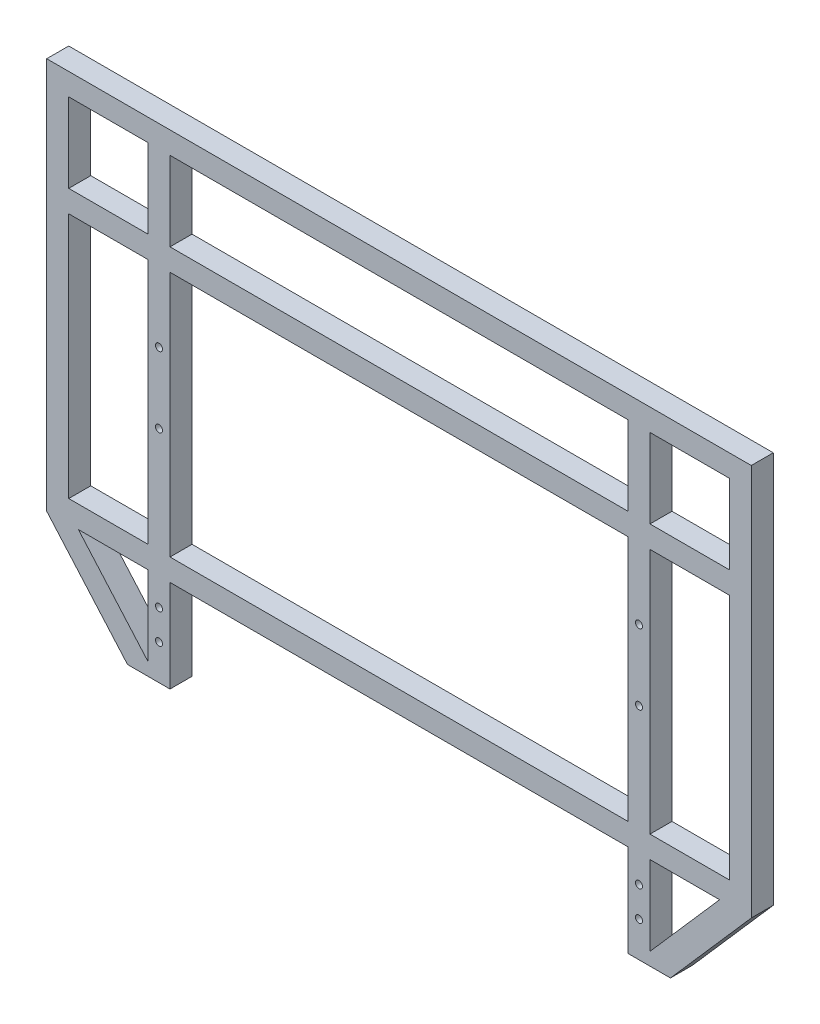
from build123d import *

# Parameters (mm, degrees)
SKETCH1_W           = 45
SKETCH1_H           = 140
SKETCH1_H_2         = 45
SKETCH1_W_2         = 260
BOSS_EXTRUDE1_DEPTH = 12.5
SKETCH2_R           = 2
CUT_EXTRUDE1_DEPTH  = 15
SKETCH3_R           = 2
CUT_EXTRUDE2_DEPTH  = 15


with BuildPart() as part:
    # Sketch1 → Boss-Extrude1 (new body)
    with BuildSketch(Plane.XY):
        Polygon((200, 0), (0, 0), (-200, 0), (-200, -222.5), (-154.126087164, -274.927328955), (-130, -274.927328955), (-130, -222.5), (130, -222.5), (130, -274.927328955), (154.126087164, -274.927328955), (200, -222.5), align=None)
        Polygon((-142.5, -267.654601682), (-182.010276472, -222.5), (-142.5, -222.5), align=None, mode=Mode.SUBTRACT)
        Polygon((142.5, -222.5), (182.010276472, -222.5), (142.5, -267.654601682), align=None, mode=Mode.SUBTRACT)
        with Locations((-165, -140)):
            Rectangle(SKETCH1_W, SKETCH1_H, mode=Mode.SUBTRACT)
        with Locations((-165, -35)):
            Rectangle(SKETCH1_W, SKETCH1_H_2, mode=Mode.SUBTRACT)
        with Locations((0, -35)):
            Rectangle(SKETCH1_W_2, SKETCH1_H_2, mode=Mode.SUBTRACT)
        with Locations((0, -140)):
            Rectangle(SKETCH1_W_2, SKETCH1_H, mode=Mode.SUBTRACT)
        with Locations((165, -140)):
            Rectangle(SKETCH1_W, SKETCH1_H, mode=Mode.SUBTRACT)
        with Locations((165, -35)):
            Rectangle(SKETCH1_W, SKETCH1_H_2, mode=Mode.SUBTRACT)
    extrude(amount=BOSS_EXTRUDE1_DEPTH)

    # Sketch2 → Cut-Extrude1 (cut)
    with BuildSketch(Plane(origin=(0, 0, 0), x_dir=(-1, 0, 0), z_dir=(0, 0, -1))):
        with Locations((136.25, -110)):
            Circle(SKETCH2_R)
        with Locations((136.25, -150)):
            Circle(SKETCH2_R)
        with Locations((-136.25, -110)):
            Circle(SKETCH2_R)
        with Locations((-136.25, -150)):
            Circle(SKETCH2_R)
    extrude(amount=-CUT_EXTRUDE1_DEPTH, mode=Mode.SUBTRACT)

    # Sketch3 → Cut-Extrude2 (cut)
    with BuildSketch(Plane.XY.offset(12.5)):
        with Locations((-136.25, -237.927328955)):
            Circle(SKETCH3_R)
        with Locations((-136.25, -254.927328955)):
            Circle(SKETCH3_R)
        with Locations((136.25, -254.927328955)):
            Circle(SKETCH3_R)
        with Locations((136.25, -237.927328955)):
            Circle(SKETCH3_R)
    extrude(amount=-CUT_EXTRUDE2_DEPTH, mode=Mode.SUBTRACT)


solid = part.part
